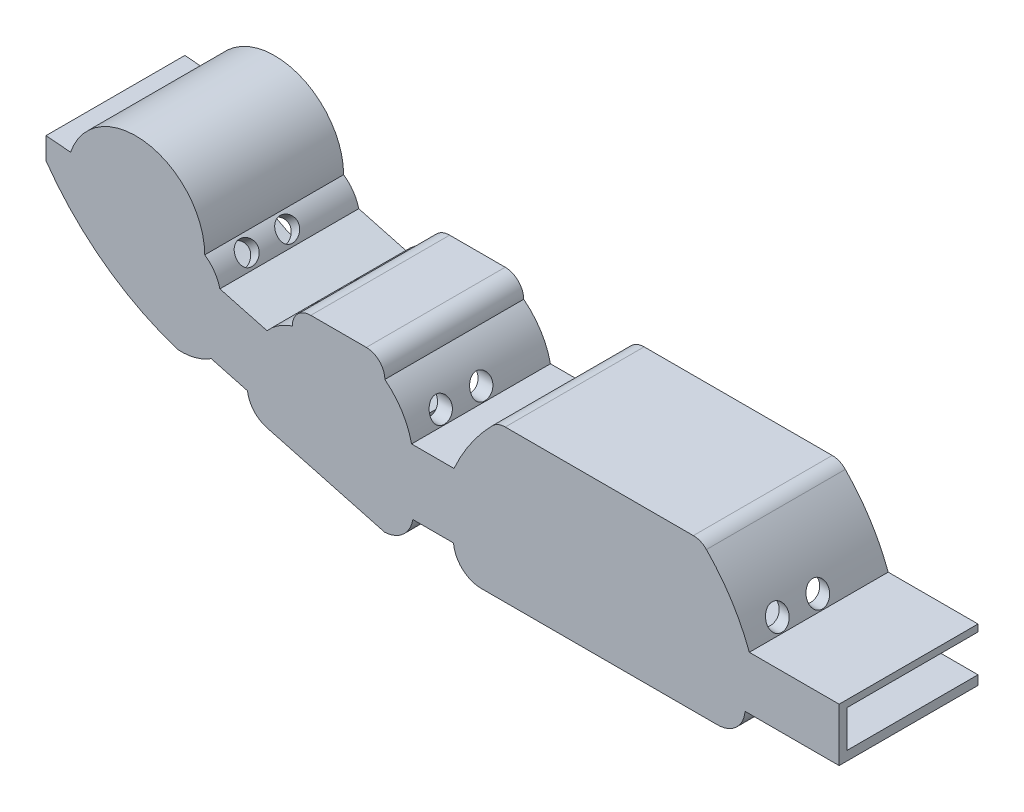
from build123d import *

# Parameters (mm, degrees)
WALLS_DEPTH                         = 16
BASE_DEPTH                          = 1
CUT_EXTRUDE2_REACH                  = 71.681
CUT_EXTRUDE2_END_RADIUS             = 7.978898039
SKETCH14_R                          = 1.4
CUT_EXTRUDE3_REACH                  = 98.991
CUT_EXTRUDE3_END_RADIUS             = 7.978898039
SKETCH15_R                          = 1.4
CUT_EXTRUDE4_REACH                  = 80.334
CUT_EXTRUDE4_END_RADIUS             = 33.443931457
SKETCH16_R                          = 1.4
CUT_EXTRUDE4_DIRECTION_2_REACH      = 80.334
CUT_EXTRUDE4_DIRECTION_2_END_RADIUS = 4.849339701
CUT_EXTRUDE5_REACH                  = 78.608
CUT_EXTRUDE5_END_RADIUS             = 6.135740623
SKETCH18_R                          = 1.4
CUT_EXTRUDE6_DEPTH                  = 1
CUT_EXTRUDE7_START                  = 1
SKETCH20_W                          = 0.5
SKETCH20_H                          = 5.968950485
CUT_EXTRUDE7_DEPTH                  = 13
CUT_EXTRUDE8_START                  = -1
SKETCH21_W                          = 1.2
SKETCH21_H                          = 4.8
CUT_EXTRUDE8_DEPTH                  = 17
BOSS_EXTRUDE7_DEPTH                 = 1


with BuildPart() as part:
    # Sketch1 → Walls (new body)
    with BuildSketch(Plane.XY):
        with BuildLine():
            Line((-2.714226626, -4.104973799), (9.481662569, -4.104973799))
            Line((9.481662569, -4.104973799), (9.481662569, 2.795026201))
            Line((9.481662569, 2.795026201), (-2.157765014, 2.795026201))
            ThreePointArc((-2.157765014, 2.795026201), (-4.475421171, 7.467506564), (-7.720187416, 11.551021571))
            ThreePointArc((-7.720187416, 11.551021571), (-8.494484922, 12.081481284), (-9.414311331, 12.268145448))
            Line((-9.414311331, 12.268145448), (-33.796800773, 12.268145448))
            ThreePointArc((-33.796800773, 12.268145448), (-34.716627182, 12.081481284), (-35.490924688, 11.551021571))
            ThreePointArc((-35.490924688, 11.551021571), (-38.29010211, 8.144207478), (-40.440818273, 4.295026201))
            Line((-40.440818273, 4.295026201), (-45.938103823, 4.295026201))
            ThreePointArc((-45.938103823, 4.295026201), (-47.188812463, 7.352239347), (-49.403987198, 9.802509784))
            ThreePointArc((-49.403987198, 9.802509784), (-50.106930923, 11.499566059), (-51.803987198, 12.202509784))
            Line((-51.803987198, 12.202509784), (-59.003987198, 12.202509784))
            ThreePointArc((-59.003987198, 12.202509784), (-60.701043473, 11.499566059), (-61.403987198, 9.802509784))
            ThreePointArc((-61.403987198, 9.802509784), (-63.184886069, 8.942613092), (-64.672674129, 7.63972791))
            Line((-64.672674129, 7.63972791), (-70.785187578, 9.280115945))
            ThreePointArc((-70.785187578, 9.280115945), (-71.505528448, 10.877592909), (-72.746606478, 12.114746473))
            ThreePointArc((-72.746606478, 12.114746473), (-80.242766302, 20.896236037), (-90.13721729, 14.945873803))
            Line((-90.13721729, 14.945873803), (-93.325677347, 15.217392614))
            Line((-93.325677347, 15.217392614), (-93.325677347, 12.385824824))
            ThreePointArc((-93.325677347, 12.385824824), (-85.806348322, 4.663063574), (-76.221084045, -0.266851135))
            ThreePointArc((-76.221084045, -0.266851135), (-73.974490708, -0.03182968), (-71.909952013, 0.884738205))
            Line((-71.909952013, 0.884738205), (-69.612719989, 0.268240269))
            Line((-69.612719989, 0.268240269), (-67.205171624, -0.377862773))
            ThreePointArc((-67.205171624, -0.377862773), (-66.313521198, -2.28542285), (-64.479036899, -3.319102342))
            Line((-64.479036899, -3.319102342), (-49.412163448, -7.362532125))
            ThreePointArc((-49.412163448, -7.362532125), (-47.023330152, -6.369383775), (-45.772204411, -4.104973799))
            Line((-45.772204411, -4.104973799), (-40.501206151, -4.104973799))
            ThreePointArc((-40.501206151, -4.104973799), (-39.353550113, -6.460513587), (-36.912978021, -7.414080542))
            Line((-36.912978021, -7.414080542), (-6.302454756, -7.414080542))
            ThreePointArc((-6.302454756, -7.414080542), (-3.861882663, -6.460513587), (-2.714226626, -4.104973799))
        make_face()
        with BuildLine():
            Line((-11.180694354, 10.652027), (-11.480694354, 9.152027))
            Line((-11.480694354, 9.152027), (-11.780694354, 10.652027))
            Line((-11.780694354, 10.652027), (-12.480694354, 10.652027))
            Line((-12.480694354, 10.652027), (-12.780694354, 9.152027))
            Line((-12.780694354, 9.152027), (-13.080694354, 10.652027))
            Line((-13.080694354, 10.652027), (-13.754684343, 10.652027))
            Line((-13.754684343, 10.652027), (-14.054684343, 9.152027))
            Line((-14.054684343, 9.152027), (-14.354684343, 10.652027))
            Line((-14.354684343, 10.652027), (-15.054684343, 10.652027))
            Line((-15.054684343, 10.652027), (-15.354684343, 9.152027))
            Line((-15.354684343, 9.152027), (-15.654684343, 10.652027))
            Line((-15.654684343, 10.652027), (-16.354684343, 10.652027))
            Line((-16.354684343, 10.652027), (-16.654684343, 9.152027))
            Line((-16.654684343, 9.152027), (-16.954684343, 10.652027))
            Line((-16.954684343, 10.652027), (-17.654684343, 10.652027))
            Line((-17.654684343, 10.652027), (-17.954684343, 9.152027))
            Line((-17.954684343, 9.152027), (-18.254684343, 10.652027))
            Line((-18.254684343, 10.652027), (-18.954684343, 10.652027))
            Line((-18.954684343, 10.652027), (-19.254684343, 9.152027))
            Line((-19.254684343, 9.152027), (-19.554684343, 10.652027))
            Line((-19.554684343, 10.652027), (-20.254684343, 10.652027))
            Line((-20.254684343, 10.652027), (-20.554684343, 9.152027))
            Line((-20.554684343, 9.152027), (-20.854684343, 10.652027))
            Line((-20.854684343, 10.652027), (-21.554684343, 10.652027))
            Line((-21.554684343, 10.652027), (-21.854684343, 9.152027))
            Line((-21.854684343, 9.152027), (-22.154684343, 10.652027))
            Line((-22.154684343, 10.652027), (-22.854684343, 10.652027))
            Line((-22.854684343, 10.652027), (-23.154684343, 9.152027))
            Line((-23.154684343, 9.152027), (-23.454684343, 10.652027))
            Line((-23.454684343, 10.652027), (-24.154684343, 10.652027))
            Line((-24.154684343, 10.652027), (-24.454684343, 9.152027))
            Line((-24.454684343, 9.152027), (-24.754684343, 10.652027))
            Line((-24.754684343, 10.652027), (-25.454684343, 10.652027))
            Line((-25.454684343, 10.652027), (-25.754684343, 9.152027))
            Line((-25.754684343, 9.152027), (-26.054684343, 10.652027))
            Line((-26.054684343, 10.652027), (-26.754684343, 10.652027))
            Line((-26.754684343, 10.652027), (-27.054684343, 9.152027))
            Line((-27.054684343, 9.152027), (-27.354684343, 10.652027))
            Line((-27.354684343, 10.652027), (-28.054684343, 10.652027))
            Line((-28.054684343, 10.652027), (-28.354684343, 9.152027))
            Line((-28.354684343, 9.152027), (-28.654684343, 10.652027))
            Line((-28.654684343, 10.652027), (-29.354684343, 10.652027))
            Line((-29.354684343, 10.652027), (-29.654684343, 9.152027))
            Line((-29.654684343, 9.152027), (-29.954684343, 10.652027))
            Line((-29.954684343, 10.652027), (-30.654684343, 10.652027))
            Line((-30.654684343, 10.652027), (-30.954684343, 9.152027))
            Line((-30.954684343, 9.152027), (-31.254684343, 10.652027))
            Line((-31.254684343, 10.652027), (-31.954684343, 10.652027))
            Line((-31.954684343, 10.652027), (-32.254684343, 9.152027))
            Line((-32.254684343, 9.152027), (-32.554684343, 10.652027))
            Line((-32.554684343, 10.652027), (-33.254684343, 10.652027))
            Line((-33.254684343, 10.652027), (-33.554684343, 9.152027))
            Line((-33.554684343, 9.152027), (-33.857941673, 10.657707986))
            ThreePointArc((-33.857941673, 10.657707986), (-34.695920105, 10.483827589), (-35.383754411, 9.974586769))
            ThreePointArc((-35.383754411, 9.974586769), (-35.743038743, 9.372290059), (-35.868103034, 8.682213628))
            ThreePointArc((-35.868103034, 8.682213628), (-38.291258334, 6.284887251), (-39.492774814, 3.095026201))
            Line((-39.492774814, 3.095026201), (-47.492774814, 3.095026201))
            ThreePointArc((-47.492774814, 3.095026201), (-48.694291294, 6.284887251), (-51.117446594, 8.682213628))
            ThreePointArc((-51.117446594, 8.682213628), (-51.703233031, 10.096427191), (-53.117446594, 10.682213628))
            Line((-53.117446594, 10.682213628), (-53.259602924, 10.682178618))
            Line((-53.259602924, 10.682178618), (-53.559602924, 9.182178618))
            Line((-53.559602924, 9.182178618), (-53.859602924, 10.682178618))
            Line((-53.859602924, 10.682178618), (-54.559602924, 10.682178618))
            Line((-54.559602924, 10.682178618), (-54.859602924, 9.182178618))
            Line((-54.859602924, 9.182178618), (-55.159602924, 10.682178618))
            Line((-55.159602924, 10.682178618), (-55.833592914, 10.682178618))
            Line((-55.833592914, 10.682178618), (-56.133592914, 9.182178618))
            Line((-56.133592914, 9.182178618), (-56.433592914, 10.682178618))
            Line((-56.433592914, 10.682178618), (-57.133592914, 10.682178618))
            Line((-57.133592914, 10.682178618), (-57.433592914, 9.182178618))
            Line((-57.433592914, 9.182178618), (-57.733592914, 10.682178618))
            Line((-57.733592914, 10.682178618), (-58.433592914, 10.682178618))
            Line((-58.433592914, 10.682178618), (-58.733592914, 9.182178618))
            Line((-58.733592914, 9.182178618), (-59.033592914, 10.682178618))
            Line((-59.033592914, 10.682178618), (-59.117446594, 10.682213628))
            ThreePointArc((-59.117446594, 10.682213628), (-60.531660156, 10.096427191), (-61.117446594, 8.682213628))
            ThreePointArc((-61.117446594, 8.682213628), (-62.903259287, 7.752660176), (-64.292067832, 6.295125468))
            Line((-64.292067832, 6.295125468), (-72.018669602, 8.368679203))
            ThreePointArc((-72.018669602, 8.368679203), (-72.571585206, 9.985898204), (-73.74355905, 11.229920016))
            ThreePointArc((-73.74355905, 11.229920016), (-73.882359005, 13.084494169), (-74.44355905, 14.857560784))
            Line((-74.44355905, 14.857560784), (-74.74355905, 12.857560784))
            Line((-74.74355905, 12.857560784), (-75.04355905, 15.955023014))
            ThreePointArc((-75.04355905, 15.955023014), (-75.376987636, 16.427873033), (-75.74355905, 16.875519278))
            Line((-75.74355905, 16.875519278), (-76.04355905, 15.675519278))
            Line((-76.04355905, 15.675519278), (-76.34355905, 17.487555249))
            ThreePointArc((-76.34355905, 17.487555249), (-76.68549923, 17.783767154), (-77.04355905, 18.060277091))
            Line((-77.04355905, 18.060277091), (-77.34355905, 16.960277091))
            Line((-77.34355905, 16.960277091), (-77.64355905, 18.457409466))
            ThreePointArc((-77.64355905, 18.457409466), (-77.98894338, 18.652985458), (-78.34355905, 18.831277439))
            Line((-78.34355905, 18.831277439), (-78.64355905, 17.831277439))
            Line((-78.64355905, 17.831277439), (-78.94355905, 19.085409669))
            ThreePointArc((-78.94355905, 19.085409669), (-79.290953429, 19.207208521), (-79.64355905, 19.312977563))
            Line((-79.64355905, 19.312977563), (-79.94355905, 18.262977563))
            Line((-79.94355905, 18.262977563), (-80.24355905, 19.453586402))
            ThreePointArc((-80.24355905, 19.453586402), (-80.592411481, 19.513414143), (-80.94355905, 19.557829923))
            Line((-80.94355905, 19.557829923), (-81.24355905, 18.457829923))
            Line((-81.24355905, 18.457829923), (-81.54355905, 19.597729108))
            ThreePointArc((-81.54355905, 19.597729108), (-81.894297473, 19.600247924), (-82.244811991, 19.58746676))
            Line((-82.244811991, 19.58746676), (-82.544811991, 18.396857922))
            Line((-82.544811991, 18.396857922), (-82.844811991, 19.529836442))
            ThreePointArc((-82.844811991, 19.529836442), (-83.195091081, 19.474995797), (-83.5426118, 19.404765549))
            Line((-83.5426118, 19.404765549), (-83.8426118, 18.147652874))
            Line((-83.8426118, 18.147652874), (-84.1426118, 19.245103414))
            ThreePointArc((-84.1426118, 19.245103414), (-84.495255794, 19.127528905), (-84.842088231, 18.993779836))
            Line((-84.842088231, 18.993779836), (-85.142088231, 17.693779836))
            Line((-85.142088231, 17.693779836), (-85.442088231, 18.716947696))
            ThreePointArc((-85.442088231, 18.716947696), (-85.796217932, 18.524190844), (-86.140238881, 18.313922832))
            Line((-86.140238881, 18.313922832), (-86.440238881, 16.813922832))
            Line((-86.440238881, 16.813922832), (-86.740238881, 17.88599014))
            ThreePointArc((-86.740238881, 17.88599014), (-87.100039352, 17.586290744), (-87.441781559, 17.266152694))
            Line((-87.441781559, 17.266152694), (-87.741781559, 15.366152694))
            Line((-87.741781559, 15.366152694), (-88.041781559, 16.599884754))
            ThreePointArc((-88.041781559, 16.599884754), (-89.145352232, 14.777174034), (-89.731367356, 12.728582111))
            ThreePointArc((-89.731367356, 12.728582111), (-90.138180255, 12.562213326), (-90.540750005, 12.385824824))
            Line((-90.540750005, 12.385824824), (-92.19851244, 13.504674103))
            Line((-92.19851244, 13.504674103), (-92.584189776, 13.945331795))
            Line((-92.584189776, 13.945331795), (-92.584189776, 13.209190532))
            Line((-92.584189776, 13.209190532), (-89.28669117, 9.26545403))
            ThreePointArc((-89.28669117, 9.26545403), (-83.580116285, 4.137190402), (-76.662994505, 0.817926775))
            ThreePointArc((-76.662994505, 0.817926775), (-74.611197396, 1.000283853), (-73.160670014, 2.462848653))
            Line((-73.160670014, 2.462848653), (-65.320034751, 0.358692257))
            ThreePointArc((-65.320034751, 0.358692257), (-64.697180114, -1.501489359), (-63.0260009, -2.528807996))
            Line((-63.0260009, -2.528807996), (-50.470273024, -5.898332815))
            ThreePointArc((-50.470273024, -5.898332815), (-48.452537425, -4.937523747), (-47.523477835, -2.904973799))
            Line((-47.523477835, -2.904973799), (-39.497095345, -2.904973799))
            ThreePointArc((-39.497095345, -2.904973799), (-38.726338138, -5.239633694), (-36.469092729, -6.214080542))
            Line((-36.469092729, -6.214080542), (-6.746340048, -6.214080542))
            ThreePointArc((-6.746340048, -6.214080542), (-4.489094638, -5.239633694), (-3.718337431, -2.904973799))
            Line((-3.718337431, -2.904973799), (8.281662569, -2.904973799))
            Line((8.281662569, -2.904973799), (8.281662569, 1.895026201))
            Line((8.281662569, 1.895026201), (-3.634781843, 1.895026201))
            ThreePointArc((-3.634781843, 1.895026201), (-4.611558125, 5.76795929), (-7.34300907, 8.682213628))
            ThreePointArc((-7.34300907, 8.682213628), (-8.12308073, 9.896738229), (-9.353170431, 10.652027))
            Line((-9.353170431, 10.652027), (-9.906704364, 10.652027))
            Line((-9.906704364, 10.652027), (-10.206704364, 9.152027))
            Line((-10.206704364, 9.152027), (-10.506704364, 10.652027))
            Line((-10.506704364, 10.652027), (-11.180694354, 10.652027))
        make_face(mode=Mode.SUBTRACT)
    extrude(amount=WALLS_DEPTH)

    # Sketch2 → Base (add)
    with BuildSketch(Plane(origin=(0, 0, 0), x_dir=(-1, 0, 0), z_dir=(0, 0, -1))):
        with BuildLine():
            Line((70.785187578, 9.280115945), (64.672674129, 7.63972791))
            ThreePointArc((64.672674129, 7.63972791), (63.184886069, 8.942613092), (61.403987198, 9.802509784))
            ThreePointArc((61.403987198, 9.802509784), (60.701043473, 11.499566059), (59.003987198, 12.202509784))
            Line((59.003987198, 12.202509784), (51.803987198, 12.202509784))
            ThreePointArc((51.803987198, 12.202509784), (50.106930923, 11.499566059), (49.403987198, 9.802509784))
            ThreePointArc((49.403987198, 9.802509784), (47.188812463, 7.352239347), (45.938103823, 4.295026201))
            Line((45.938103823, 4.295026201), (40.440818273, 4.295026201))
            ThreePointArc((40.440818273, 4.295026201), (38.29010211, 8.144207478), (35.490924688, 11.551021571))
            ThreePointArc((35.490924688, 11.551021571), (34.716627182, 12.081481284), (33.796800773, 12.268145448))
            Line((33.796800773, 12.268145448), (9.414311331, 12.268145448))
            ThreePointArc((9.414311331, 12.268145448), (8.494484922, 12.081481284), (7.720187416, 11.551021571))
            ThreePointArc((7.720187416, 11.551021571), (4.475421171, 7.467506564), (2.157765014, 2.795026201))
            Line((2.157765014, 2.795026201), (-9.481662569, 2.795026201))
            Line((-9.481662569, 2.795026201), (-9.481662569, -4.104973799))
            Line((-9.481662569, -4.104973799), (2.714226626, -4.104973799))
            ThreePointArc((2.714226626, -4.104973799), (3.861882663, -6.460513587), (6.302454756, -7.414080542))
            Line((6.302454756, -7.414080542), (36.912978021, -7.414080542))
            ThreePointArc((36.912978021, -7.414080542), (39.353550113, -6.460513587), (40.501206151, -4.104973799))
            Line((40.501206151, -4.104973799), (45.772204411, -4.104973799))
            ThreePointArc((45.772204411, -4.104973799), (47.023330152, -6.369383775), (49.412163448, -7.362532125))
            Line((49.412163448, -7.362532125), (64.479036899, -3.319102342))
            ThreePointArc((64.479036899, -3.319102342), (66.313521198, -2.28542285), (67.205171624, -0.377862773))
            Line((67.205171624, -0.377862773), (71.909952013, 0.884738205))
            ThreePointArc((71.909952013, 0.884738205), (73.974490708, -0.03182968), (76.221084045, -0.266851135))
            ThreePointArc((76.221084045, -0.266851135), (85.806348322, 4.663063574), (93.325677347, 12.385824824))
            Line((93.325677347, 12.385824824), (93.325677347, 15.217392614))
            Line((93.325677347, 15.217392614), (90.13721729, 14.945873803))
            ThreePointArc((90.13721729, 14.945873803), (80.242766302, 20.896236037), (72.746606478, 12.114746473))
            ThreePointArc((72.746606478, 12.114746473), (71.505528448, 10.877592909), (70.785187578, 9.280115945))
        make_face()
    extrude(amount=BASE_DEPTH)

    # Cut-Extrude2: up to this cylinder (the profile starts outside it)
    cut_extrude2_end = Plane(origin=(-31.597572731, 1.942377959, 10.125), z_dir=(0, 0, -1)) * Cylinder(CUT_EXTRUDE2_END_RADIUS, 165.569796077, mode=Mode.PRIVATE)
    # Sketch14 → Cut-Extrude2 (cut, up to the surface)
    with BuildSketch(Plane(origin=(-55, 0, 0), x_dir=(0, 0, -1), z_dir=(1, 0, 0)), mode=Mode.PRIVATE) as cut_extrude2_sk1:
        with Locations(Location((-12.75, 5.771124661, 0), (0, 0, 180))):
            Circle(SKETCH14_R)
    cut_extrude2_tool1 = extrude(cut_extrude2_sk1.sketch, amount=CUT_EXTRUDE2_REACH, mode=Mode.PRIVATE) - cut_extrude2_end
    add(cut_extrude2_tool1.solids().sort_by_distance((-55, 5.771125, 12.75))[0], mode=Mode.SUBTRACT)
    # Sketch14 → Cut-Extrude2 (cut, up to the surface)
    with BuildSketch(Plane(origin=(-55, 0, 0), x_dir=(0, 0, -1), z_dir=(1, 0, 0)), mode=Mode.PRIVATE) as cut_extrude2_sk2:
        with Locations(Location((-7.5, 5.771124661, 0), (0, 0, 180))):
            Circle(SKETCH14_R)
    cut_extrude2_tool2 = extrude(cut_extrude2_sk2.sketch, amount=CUT_EXTRUDE2_REACH, mode=Mode.PRIVATE) - cut_extrude2_end
    add(cut_extrude2_tool2.solids().sort_by_distance((-55, 5.771125, 7.5))[0], mode=Mode.SUBTRACT)

    # Cut-Extrude3: up to this cylinder (the profile starts outside it)
    cut_extrude3_end = Plane(origin=(-11.613539373, 1.942377959, 10.125), z_dir=(0, 0, -1)) * Cylinder(CUT_EXTRUDE3_END_RADIUS, 220.189796077, mode=Mode.PRIVATE)
    # Sketch15 → Cut-Extrude3 (cut, up to the surface)
    with BuildSketch(Plane(origin=(0, 0, 0), x_dir=(0, 0, -1), z_dir=(1, 0, 0)), mode=Mode.PRIVATE) as cut_extrude3_sk1:
        with Locations((-12.75, 4.295026201)):
            Circle(SKETCH15_R)
    cut_extrude3_tool1 = extrude(cut_extrude3_sk1.sketch, amount=-CUT_EXTRUDE3_REACH, mode=Mode.PRIVATE) - cut_extrude3_end
    add(cut_extrude3_tool1.solids().sort_by_distance((0, 4.295026, 12.75))[0], mode=Mode.SUBTRACT)
    # Sketch15 → Cut-Extrude3 (cut, up to the surface)
    with BuildSketch(Plane(origin=(0, 0, 0), x_dir=(0, 0, -1), z_dir=(1, 0, 0)), mode=Mode.PRIVATE) as cut_extrude3_sk2:
        with Locations((-7.5, 4.295026201)):
            Circle(SKETCH15_R)
    cut_extrude3_tool2 = extrude(cut_extrude3_sk2.sketch, amount=-CUT_EXTRUDE3_REACH, mode=Mode.PRIVATE) - cut_extrude3_end
    add(cut_extrude3_tool2.solids().sort_by_distance((0, 4.295026, 7.5))[0], mode=Mode.SUBTRACT)

    # Cut-Extrude4: up to this cylinder (the profile starts inside it)
    cut_extrude4_end = Plane(origin=(-65.917257268, 31.550246549, 10.125), z_dir=(0, 0, -1)) * Cylinder(CUT_EXTRUDE4_END_RADIUS, 233.805862914, mode=Mode.PRIVATE)
    # Sketch16 → Cut-Extrude4 (cut, up to the surface)
    with BuildSketch(Plane(origin=(-36.996590739, -31.019345092, 0), x_dir=(0, 0, -1), z_dir=(0.7662940611199272, 0.6424900091770529, 0)), mode=Mode.PRIVATE) as cut_extrude4_sk1:
        with Locations(Location((-12.75, 54.306249845, 0), (0, 0, 90))):
            Circle(SKETCH16_R)
    cut_extrude4_tool1 = extrude(cut_extrude4_sk1.sketch, amount=-CUT_EXTRUDE4_REACH, mode=Mode.PRIVATE) & cut_extrude4_end
    add(cut_extrude4_tool1.solids().sort_by_distance((-71.887814, 10.595212, 12.75))[0], mode=Mode.SUBTRACT)
    # Sketch16 → Cut-Extrude4 (cut, up to the surface)
    with BuildSketch(Plane(origin=(-36.996590739, -31.019345092, 0), x_dir=(0, 0, -1), z_dir=(0.7662940611199272, 0.6424900091770529, 0)), mode=Mode.PRIVATE) as cut_extrude4_sk2:
        with Locations(Location((-7.5, 54.306249845, 0), (0, 0, 90))):
            Circle(SKETCH16_R)
    cut_extrude4_tool2 = extrude(cut_extrude4_sk2.sketch, amount=-CUT_EXTRUDE4_REACH, mode=Mode.PRIVATE) & cut_extrude4_end
    add(cut_extrude4_tool2.solids().sort_by_distance((-71.887814, 10.595212, 7.5))[0], mode=Mode.SUBTRACT)

    # Cut-Extrude4 direction 2: up to this cylinder (the profile starts inside it)
    cut_extrude4_direction_2_end = Plane(origin=(-75.49328755, 8.118268196, 10.125), z_dir=(0, 0, -1)) * Cylinder(CUT_EXTRUDE4_DIRECTION_2_END_RADIUS, 176.616679402, mode=Mode.PRIVATE)
    # Sketch16 → Cut-Extrude4 direction 2 (cut, up to the surface)
    with BuildSketch(Plane(origin=(-36.996590739, -31.019345092, 0), x_dir=(0, 0, -1), z_dir=(0.7662940611199272, 0.6424900091770529, 0)), mode=Mode.PRIVATE) as cut_extrude4_direction_2_sk1:
        with Locations(Location((-12.75, 54.306249845, 0), (0, 0, 90))):
            Circle(SKETCH16_R)
    cut_extrude4_direction_2_tool1 = extrude(cut_extrude4_direction_2_sk1.sketch, amount=CUT_EXTRUDE4_DIRECTION_2_REACH, mode=Mode.PRIVATE) & cut_extrude4_direction_2_end
    add(cut_extrude4_direction_2_tool1.solids().sort_by_distance((-71.887814, 10.595212, 12.75))[0], mode=Mode.SUBTRACT)
    # Sketch16 → Cut-Extrude4 direction 2 (cut, up to the surface)
    with BuildSketch(Plane(origin=(-36.996590739, -31.019345092, 0), x_dir=(0, 0, -1), z_dir=(0.7662940611199272, 0.6424900091770529, 0)), mode=Mode.PRIVATE) as cut_extrude4_direction_2_sk2:
        with Locations(Location((-7.5, 54.306249845, 0), (0, 0, 90))):
            Circle(SKETCH16_R)
    cut_extrude4_direction_2_tool2 = extrude(cut_extrude4_direction_2_sk2.sketch, amount=CUT_EXTRUDE4_DIRECTION_2_REACH, mode=Mode.PRIVATE) & cut_extrude4_direction_2_end
    add(cut_extrude4_direction_2_tool2.solids().sort_by_distance((-71.887814, 10.595212, 7.5))[0], mode=Mode.SUBTRACT)

    # Cut-Extrude5: up to this cylinder (the profile starts outside it)
    cut_extrude5_end = Plane(origin=(-59.215764964, 2.84861097, 10.125), z_dir=(0, 0, -1)) * Cylinder(CUT_EXTRUDE5_END_RADIUS, 175.737481246, mode=Mode.PRIVATE)
    # Sketch18 → Cut-Extrude5 (cut, up to the surface)
    with BuildSketch(Plane(origin=(-59.548887405, 21.700220756, 0), x_dir=(0, 0, -1), z_dir=(-0.9395597001849877, 0.34238511911047786, 0)), mode=Mode.PRIVATE) as cut_extrude5_sk1:
        with Locations(Location((-12.75, 12.958307694, 0), (0, 0, 187.802493241))):
            Circle(SKETCH18_R)
    cut_extrude5_tool1 = extrude(cut_extrude5_sk1.sketch, amount=-CUT_EXTRUDE5_REACH, mode=Mode.PRIVATE) - cut_extrude5_end
    add(cut_extrude5_tool1.solids().sort_by_distance((-63.985619, 9.525117, 12.75))[0], mode=Mode.SUBTRACT)
    # Sketch18 → Cut-Extrude5 (cut, up to the surface)
    with BuildSketch(Plane(origin=(-59.548887405, 21.700220756, 0), x_dir=(0, 0, -1), z_dir=(-0.9395597001849877, 0.34238511911047786, 0)), mode=Mode.PRIVATE) as cut_extrude5_sk2:
        with Locations(Location((-7.5, 12.958307694, 0), (0, 0, 352.19753415))):
            Circle(SKETCH18_R)
    cut_extrude5_tool2 = extrude(cut_extrude5_sk2.sketch, amount=-CUT_EXTRUDE5_REACH, mode=Mode.PRIVATE) - cut_extrude5_end
    add(cut_extrude5_tool2.solids().sort_by_distance((-63.985619, 9.525117, 7.5))[0], mode=Mode.SUBTRACT)

    # Sketch19 → Cut-Extrude6 (cut)
    with BuildSketch(Plane.XY):
        with BuildLine():
            Line((-11.180694354, 10.652027), (-11.480694354, 9.152027))
            Line((-11.480694354, 9.152027), (-11.780694354, 10.652027))
            Line((-11.780694354, 10.652027), (-12.480694354, 10.652027))
            Line((-12.480694354, 10.652027), (-12.780694354, 9.152027))
            Line((-12.780694354, 9.152027), (-13.080694354, 10.652027))
            Line((-13.080694354, 10.652027), (-13.754684343, 10.652027))
            Line((-13.754684343, 10.652027), (-14.054684343, 9.152027))
            Line((-14.054684343, 9.152027), (-14.354684343, 10.652027))
            Line((-14.354684343, 10.652027), (-15.054684343, 10.652027))
            Line((-15.054684343, 10.652027), (-15.354684343, 9.152027))
            Line((-15.354684343, 9.152027), (-15.654684343, 10.652027))
            Line((-15.654684343, 10.652027), (-16.354684343, 10.652027))
            Line((-16.354684343, 10.652027), (-16.654684343, 9.152027))
            Line((-16.654684343, 9.152027), (-16.954684343, 10.652027))
            Line((-16.954684343, 10.652027), (-17.654684343, 10.652027))
            Line((-17.654684343, 10.652027), (-17.954684343, 9.152027))
            Line((-17.954684343, 9.152027), (-18.254684343, 10.652027))
            Line((-18.254684343, 10.652027), (-18.954684343, 10.652027))
            Line((-18.954684343, 10.652027), (-19.254684343, 9.152027))
            Line((-19.254684343, 9.152027), (-19.554684343, 10.652027))
            Line((-19.554684343, 10.652027), (-20.254684343, 10.652027))
            Line((-20.254684343, 10.652027), (-20.554684343, 9.152027))
            Line((-20.554684343, 9.152027), (-20.854684343, 10.652027))
            Line((-20.854684343, 10.652027), (-21.554684343, 10.652027))
            Line((-21.554684343, 10.652027), (-21.854684343, 9.152027))
            Line((-21.854684343, 9.152027), (-22.154684343, 10.652027))
            Line((-22.154684343, 10.652027), (-22.854684343, 10.652027))
            Line((-22.854684343, 10.652027), (-23.154684343, 9.152027))
            Line((-23.154684343, 9.152027), (-23.454684343, 10.652027))
            Line((-23.454684343, 10.652027), (-24.154684343, 10.652027))
            Line((-24.154684343, 10.652027), (-24.454684343, 9.152027))
            Line((-24.454684343, 9.152027), (-24.754684343, 10.652027))
            Line((-24.754684343, 10.652027), (-25.454684343, 10.652027))
            Line((-25.454684343, 10.652027), (-25.754684343, 9.152027))
            Line((-25.754684343, 9.152027), (-26.054684343, 10.652027))
            Line((-26.054684343, 10.652027), (-26.754684343, 10.652027))
            Line((-26.754684343, 10.652027), (-27.054684343, 9.152027))
            Line((-27.054684343, 9.152027), (-27.354684343, 10.652027))
            Line((-27.354684343, 10.652027), (-28.054684343, 10.652027))
            Line((-28.054684343, 10.652027), (-28.354684343, 9.152027))
            Line((-28.354684343, 9.152027), (-28.654684343, 10.652027))
            Line((-28.654684343, 10.652027), (-29.354684343, 10.652027))
            Line((-29.354684343, 10.652027), (-29.654684343, 9.152027))
            Line((-29.654684343, 9.152027), (-29.954684343, 10.652027))
            Line((-29.954684343, 10.652027), (-30.654684343, 10.652027))
            Line((-30.654684343, 10.652027), (-30.954684343, 9.152027))
            Line((-30.954684343, 9.152027), (-31.254684343, 10.652027))
            Line((-31.254684343, 10.652027), (-31.954684343, 10.652027))
            Line((-31.954684343, 10.652027), (-32.254684343, 9.152027))
            Line((-32.254684343, 9.152027), (-32.554684343, 10.652027))
            Line((-32.554684343, 10.652027), (-33.254684343, 10.652027))
            Line((-33.254684343, 10.652027), (-33.554684343, 9.152027))
            Line((-33.554684343, 9.152027), (-33.857941673, 10.657707986))
            ThreePointArc((-33.857941673, 10.657707986), (-34.695920105, 10.483827589), (-35.383754411, 9.974586769))
            ThreePointArc((-35.383754411, 9.974586769), (-35.743038743, 9.372290059), (-35.868103034, 8.682213628))
            ThreePointArc((-35.868103034, 8.682213628), (-38.291258334, 6.284887251), (-39.492774814, 3.095026201))
            Line((-39.492774814, 3.095026201), (-47.492774814, 3.095026201))
            ThreePointArc((-47.492774814, 3.095026201), (-48.694291294, 6.284887251), (-51.117446594, 8.682213628))
            ThreePointArc((-51.117446594, 8.682213628), (-51.703233031, 10.096427191), (-53.117446594, 10.682213628))
            Line((-53.117446594, 10.682213628), (-53.259602924, 10.682178618))
            Line((-53.259602924, 10.682178618), (-53.559602924, 9.182178618))
            Line((-53.559602924, 9.182178618), (-53.859602924, 10.682178618))
            Line((-53.859602924, 10.682178618), (-54.559602924, 10.682178618))
            Line((-54.559602924, 10.682178618), (-54.859602924, 9.182178618))
            Line((-54.859602924, 9.182178618), (-55.159602924, 10.682178618))
            Line((-55.159602924, 10.682178618), (-55.833592914, 10.682178618))
            Line((-55.833592914, 10.682178618), (-56.133592914, 9.182178618))
            Line((-56.133592914, 9.182178618), (-56.433592914, 10.682178618))
            Line((-56.433592914, 10.682178618), (-57.133592914, 10.682178618))
            Line((-57.133592914, 10.682178618), (-57.433592914, 9.182178618))
            Line((-57.433592914, 9.182178618), (-57.733592914, 10.682178618))
            Line((-57.733592914, 10.682178618), (-58.433592914, 10.682178618))
            Line((-58.433592914, 10.682178618), (-58.733592914, 9.182178618))
            Line((-58.733592914, 9.182178618), (-59.033592914, 10.682178618))
            Line((-59.033592914, 10.682178618), (-59.117446594, 10.682213628))
            ThreePointArc((-59.117446594, 10.682213628), (-60.531660156, 10.096427191), (-61.117446594, 8.682213628))
            ThreePointArc((-61.117446594, 8.682213628), (-62.903259287, 7.752660176), (-64.292067832, 6.295125468))
            Line((-64.292067832, 6.295125468), (-72.018669602, 8.368679203))
            ThreePointArc((-72.018669602, 8.368679203), (-72.571585206, 9.985898204), (-73.74355905, 11.229920016))
            ThreePointArc((-73.74355905, 11.229920016), (-73.882359005, 13.084494169), (-74.44355905, 14.857560784))
            Line((-74.44355905, 14.857560784), (-74.74355905, 12.857560784))
            Line((-74.74355905, 12.857560784), (-75.04355905, 15.955023014))
            ThreePointArc((-75.04355905, 15.955023014), (-75.376987636, 16.427873033), (-75.74355905, 16.875519278))
            Line((-75.74355905, 16.875519278), (-76.04355905, 15.675519278))
            Line((-76.04355905, 15.675519278), (-76.34355905, 17.487555249))
            ThreePointArc((-76.34355905, 17.487555249), (-76.68549923, 17.783767154), (-77.04355905, 18.060277091))
            Line((-77.04355905, 18.060277091), (-77.34355905, 16.960277091))
            Line((-77.34355905, 16.960277091), (-77.64355905, 18.457409466))
            ThreePointArc((-77.64355905, 18.457409466), (-77.98894338, 18.652985458), (-78.34355905, 18.831277439))
            Line((-78.34355905, 18.831277439), (-78.64355905, 17.831277439))
            Line((-78.64355905, 17.831277439), (-78.94355905, 19.085409669))
            ThreePointArc((-78.94355905, 19.085409669), (-79.290953429, 19.207208521), (-79.64355905, 19.312977563))
            Line((-79.64355905, 19.312977563), (-79.94355905, 18.262977563))
            Line((-79.94355905, 18.262977563), (-80.24355905, 19.453586402))
            ThreePointArc((-80.24355905, 19.453586402), (-80.592411481, 19.513414143), (-80.94355905, 19.557829923))
            Line((-80.94355905, 19.557829923), (-81.24355905, 18.457829923))
            Line((-81.24355905, 18.457829923), (-81.54355905, 19.597729108))
            ThreePointArc((-81.54355905, 19.597729108), (-81.894297473, 19.600247924), (-82.244811991, 19.58746676))
            Line((-82.244811991, 19.58746676), (-82.544811991, 18.396857922))
            Line((-82.544811991, 18.396857922), (-82.844811991, 19.529836442))
            ThreePointArc((-82.844811991, 19.529836442), (-83.195091081, 19.474995797), (-83.5426118, 19.404765549))
            Line((-83.5426118, 19.404765549), (-83.8426118, 18.147652874))
            Line((-83.8426118, 18.147652874), (-84.1426118, 19.245103414))
            ThreePointArc((-84.1426118, 19.245103414), (-84.495255794, 19.127528905), (-84.842088231, 18.993779836))
            Line((-84.842088231, 18.993779836), (-85.142088231, 17.693779836))
            Line((-85.142088231, 17.693779836), (-85.442088231, 18.716947696))
            ThreePointArc((-85.442088231, 18.716947696), (-85.796217932, 18.524190844), (-86.140238881, 18.313922832))
            Line((-86.140238881, 18.313922832), (-86.440238881, 16.813922832))
            Line((-86.440238881, 16.813922832), (-86.740238881, 17.88599014))
            ThreePointArc((-86.740238881, 17.88599014), (-87.100039352, 17.586290744), (-87.441781559, 17.266152694))
            Line((-87.441781559, 17.266152694), (-87.741781559, 15.366152694))
            Line((-87.741781559, 15.366152694), (-88.041781559, 16.599884754))
            ThreePointArc((-88.041781559, 16.599884754), (-89.145352232, 14.777174034), (-89.731367356, 12.728582111))
            ThreePointArc((-89.731367356, 12.728582111), (-90.138180255, 12.562213326), (-90.540750005, 12.385824824))
            Line((-90.540750005, 12.385824824), (-92.19851244, 13.504674103))
            Line((-92.19851244, 13.504674103), (-92.584189776, 13.945331795))
            Line((-92.584189776, 13.945331795), (-92.584189776, 13.209190532))
            Line((-92.584189776, 13.209190532), (-89.28669117, 9.26545403))
            ThreePointArc((-89.28669117, 9.26545403), (-83.580116285, 4.137190402), (-76.662994505, 0.817926775))
            ThreePointArc((-76.662994505, 0.817926775), (-74.611197396, 1.000283853), (-73.160670014, 2.462848653))
            Line((-73.160670014, 2.462848653), (-65.320034751, 0.358692257))
            ThreePointArc((-65.320034751, 0.358692257), (-64.697180114, -1.501489359), (-63.0260009, -2.528807996))
            Line((-63.0260009, -2.528807996), (-50.470273024, -5.898332815))
            ThreePointArc((-50.470273024, -5.898332815), (-48.452537425, -4.937523747), (-47.523477835, -2.904973799))
            Line((-47.523477835, -2.904973799), (-39.497095345, -2.904973799))
            ThreePointArc((-39.497095345, -2.904973799), (-38.726338138, -5.239633694), (-36.469092729, -6.214080542))
            Line((-36.469092729, -6.214080542), (-6.746340048, -6.214080542))
            ThreePointArc((-6.746340048, -6.214080542), (-4.489094638, -5.239633694), (-3.718337431, -2.904973799))
            Line((-3.718337431, -2.904973799), (8.281662569, -2.904973799))
            Line((8.281662569, -2.904973799), (8.281662569, 1.895026201))
            Line((8.281662569, 1.895026201), (-3.634781843, 1.895026201))
            ThreePointArc((-3.634781843, 1.895026201), (-4.611558125, 5.76795929), (-7.34300907, 8.682213628))
            ThreePointArc((-7.34300907, 8.682213628), (-8.12308073, 9.896738229), (-9.353170431, 10.652027))
            Line((-9.353170431, 10.652027), (-9.906704364, 10.652027))
            Line((-9.906704364, 10.652027), (-10.206704364, 9.152027))
            Line((-10.206704364, 9.152027), (-10.506704364, 10.652027))
            Line((-10.506704364, 10.652027), (-11.180694354, 10.652027))
        make_face()
    extrude(amount=-CUT_EXTRUDE6_DEPTH, mode=Mode.SUBTRACT)

    # Sketch20 → Cut-Extrude7 (cut)
    with BuildSketch(Plane.XY.offset(CUT_EXTRUDE7_START)):
        Polygon((-90.379271747, 6.011586265), (-87.900305026, 8.428703375), (-87.566034878, 8.05629214), (-90.030212458, 5.653595186), align=None)
        Polygon((-57.302526001, -6.240081515), (-56.214991066, -2.187642835), (-55.732078455, -2.317239943), (-56.819613391, -6.369678623), align=None)
        Polygon((-78.65878615, 2.18354453), (-79.690367789, -0.551879915), (-79.222529992, -0.728310627), (-78.190948353, 2.007113819), align=None)
        with Locations((-24.497959011, -7.165975116)):
            Rectangle(SKETCH20_W, SKETCH20_H)
    extrude(amount=CUT_EXTRUDE7_DEPTH, mode=Mode.SUBTRACT)

    # Sketch21 → Cut-Extrude8 (cut)
    with BuildSketch(Plane.XY.offset(CUT_EXTRUDE8_START)):
        with Locations((8.881662569, -0.504973799)):
            Rectangle(SKETCH21_W, SKETCH21_H)
    extrude(amount=CUT_EXTRUDE8_DEPTH, mode=Mode.SUBTRACT)

    # Sketch22 → Boss-Extrude7 (add)
    with BuildSketch(Plane.XY.offset(16)):
        with BuildLine():
            Line((-2.714226626, -4.104973799), (9.481662569, -4.104973799))
            Line((9.481662569, -4.104973799), (9.481662569, 2.795026201))
            Line((9.481662569, 2.795026201), (-2.157765014, 2.795026201))
            ThreePointArc((-2.157765014, 2.795026201), (-4.475421171, 7.467506564), (-7.720187416, 11.551021571))
            ThreePointArc((-7.720187416, 11.551021571), (-8.494484922, 12.081481284), (-9.414311331, 12.268145448))
            Line((-9.414311331, 12.268145448), (-33.796800773, 12.268145448))
            ThreePointArc((-33.796800773, 12.268145448), (-34.716627182, 12.081481284), (-35.490924688, 11.551021571))
            ThreePointArc((-35.490924688, 11.551021571), (-38.29010211, 8.144207478), (-40.440818273, 4.295026201))
            Line((-40.440818273, 4.295026201), (-45.938103823, 4.295026201))
            ThreePointArc((-45.938103823, 4.295026201), (-47.188812463, 7.352239347), (-49.403987198, 9.802509784))
            ThreePointArc((-49.403987198, 9.802509784), (-50.106930923, 11.499566059), (-51.803987198, 12.202509784))
            Line((-51.803987198, 12.202509784), (-59.003987198, 12.202509784))
            ThreePointArc((-59.003987198, 12.202509784), (-60.701043473, 11.499566059), (-61.403987198, 9.802509784))
            ThreePointArc((-61.403987198, 9.802509784), (-63.184886069, 8.942613092), (-64.672674129, 7.63972791))
            Line((-64.672674129, 7.63972791), (-70.785187578, 9.280115945))
            ThreePointArc((-70.785187578, 9.280115945), (-71.505528448, 10.877592909), (-72.746606478, 12.114746473))
            ThreePointArc((-72.746606478, 12.114746473), (-80.242766302, 20.896236037), (-90.13721729, 14.945873803))
            Line((-90.13721729, 14.945873803), (-93.325677347, 15.217392614))
            Line((-93.325677347, 15.217392614), (-93.325677347, 12.385824824))
            ThreePointArc((-93.325677347, 12.385824824), (-85.806348322, 4.663063574), (-76.221084045, -0.266851135))
            ThreePointArc((-76.221084045, -0.266851135), (-73.974490708, -0.03182968), (-71.909952013, 0.884738205))
            Line((-71.909952013, 0.884738205), (-69.612719989, 0.268240269))
            Line((-69.612719989, 0.268240269), (-67.205171624, -0.377862773))
            ThreePointArc((-67.205171624, -0.377862773), (-66.313521198, -2.28542285), (-64.479036899, -3.319102342))
            Line((-64.479036899, -3.319102342), (-49.412163448, -7.362532125))
            ThreePointArc((-49.412163448, -7.362532125), (-47.023330152, -6.369383775), (-45.772204411, -4.104973799))
            Line((-45.772204411, -4.104973799), (-40.501206151, -4.104973799))
            ThreePointArc((-40.501206151, -4.104973799), (-39.353550113, -6.460513587), (-36.912978021, -7.414080542))
            Line((-36.912978021, -7.414080542), (-6.302454756, -7.414080542))
            ThreePointArc((-6.302454756, -7.414080542), (-3.861882663, -6.460513587), (-2.714226626, -4.104973799))
        make_face()
    extrude(amount=BOSS_EXTRUDE7_DEPTH)


solid = part.part
